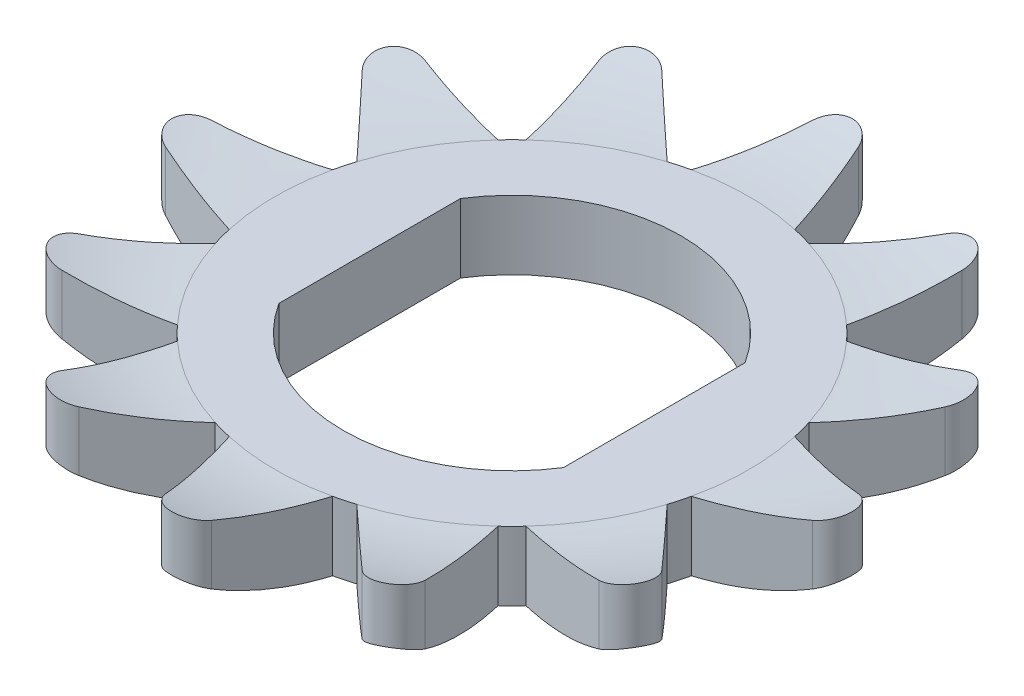
from build123d import *

# Parameters (mm, degrees)
BOSS_EXTRUDE1_DEPTH = 2.45
CUT_EXTRUDE1_DEPTH  = 2.45


with BuildPart() as part:
    # Sketch1 → Boss-Extrude1 (new body)
    with BuildSketch(Plane(origin=(0, 0, 0), x_dir=(1, 0, 0), z_dir=(0, 1, 0))):
        with BuildLine():
            Line((-1.5, 6.70936845), (-0.668522477, 9.387551675))
            ThreePointArc((-0.668522477, 9.387551675), (0, 9.88), (0.668522477, 9.387551675))
            Line((0.668522477, 9.387551675), (1.5, 6.70936845))
            ThreePointArc((1.5, 6.70936845), (1.779380935, 6.640740056), (2.055646119, 6.560483521))
            Line((2.055646119, 6.560483521), (4.114818389, 8.464119468))
            ThreePointArc((4.114818389, 8.464119468), (4.94, 8.556330989), (5.272733285, 7.795596991))
            Line((5.272733285, 7.795596991), (4.653722331, 5.060483521))
            ThreePointArc((4.653722331, 5.060483521), (4.861359121, 4.861359121), (5.060483521, 4.653722331))
            Line((5.060483521, 4.653722331), (7.795596991, 5.272733285))
            ThreePointArc((7.795596991, 5.272733285), (8.556330989, 4.94), (8.464119468, 4.114818389))
            Line((8.464119468, 4.114818389), (6.560483521, 2.055646119))
            ThreePointArc((6.560483521, 2.055646119), (6.640740056, 1.779380935), (6.70936845, 1.5))
            Line((6.70936845, 1.5), (9.387551675, 0.668522477))
            ThreePointArc((9.387551675, 0.668522477), (9.88, 0), (9.387551675, -0.668522477))
            Line((9.387551675, -0.668522477), (6.70936845, -1.5))
            ThreePointArc((6.70936845, -1.5), (6.640740056, -1.779380935), (6.560483521, -2.055646119))
            Line((6.560483521, -2.055646119), (8.464119468, -4.114818389))
            ThreePointArc((8.464119468, -4.114818389), (8.556330989, -4.94), (7.795596991, -5.272733285))
            Line((7.795596991, -5.272733285), (5.060483521, -4.653722331))
            ThreePointArc((5.060483521, -4.653722331), (4.861359121, -4.861359121), (4.653722331, -5.060483521))
            Line((4.653722331, -5.060483521), (5.272733285, -7.795596991))
            ThreePointArc((5.272733285, -7.795596991), (4.94, -8.556330989), (4.114818389, -8.464119468))
            Line((4.114818389, -8.464119468), (2.055646119, -6.560483521))
            ThreePointArc((2.055646119, -6.560483521), (1.779380935, -6.640740056), (1.5, -6.70936845))
            Line((1.5, -6.70936845), (0.668522477, -9.387551675))
            ThreePointArc((0.668522477, -9.387551675), (0, -9.88), (-0.668522477, -9.387551675))
            Line((-0.668522477, -9.387551675), (-1.5, -6.70936845))
            ThreePointArc((-1.5, -6.70936845), (-1.779380935, -6.640740056), (-2.055646119, -6.560483521))
            Line((-2.055646119, -6.560483521), (-4.114818389, -8.464119468))
            ThreePointArc((-4.114818389, -8.464119468), (-4.94, -8.556330989), (-5.272733285, -7.795596991))
            Line((-5.272733285, -7.795596991), (-4.653722331, -5.060483521))
            ThreePointArc((-4.653722331, -5.060483521), (-4.861359121, -4.861359121), (-5.060483521, -4.653722331))
            Line((-5.060483521, -4.653722331), (-7.795596991, -5.272733285))
            ThreePointArc((-7.795596991, -5.272733285), (-8.556330989, -4.94), (-8.464119468, -4.114818389))
            Line((-8.464119468, -4.114818389), (-6.560483521, -2.055646119))
            ThreePointArc((-6.560483521, -2.055646119), (-6.640740056, -1.779380935), (-6.70936845, -1.5))
            Line((-6.70936845, -1.5), (-9.387551675, -0.668522477))
            ThreePointArc((-9.387551675, -0.668522477), (-9.88, 0), (-9.387551675, 0.668522477))
            Line((-9.387551675, 0.668522477), (-6.70936845, 1.5))
            ThreePointArc((-6.70936845, 1.5), (-6.640740056, 1.779380935), (-6.560483521, 2.055646119))
            Line((-6.560483521, 2.055646119), (-8.464119468, 4.114818389))
            ThreePointArc((-8.464119468, 4.114818389), (-8.556330989, 4.94), (-7.795596991, 5.272733285))
            Line((-7.795596991, 5.272733285), (-5.060483521, 4.653722331))
            ThreePointArc((-5.060483521, 4.653722331), (-4.861359121, 4.861359121), (-4.653722331, 5.060483521))
            Line((-4.653722331, 5.060483521), (-5.272733285, 7.795596991))
            ThreePointArc((-5.272733285, 7.795596991), (-4.94, 8.556330989), (-4.114818389, 8.464119468))
            Line((-4.114818389, 8.464119468), (-2.055646119, 6.560483521))
            ThreePointArc((-2.055646119, 6.560483521), (-1.779380935, 6.640740056), (-1.5, 6.70936845))
        make_face()
    extrude(amount=BOSS_EXTRUDE1_DEPTH)

    # Sketch2 → Cut-Revolve1 (revolve, cut)
    with BuildSketch(Plane(origin=(0, 0, 0), x_dir=(0, 0, -1), z_dir=(1, 0, 0))):
        with BuildLine():
            Line((-6.875, 0), (-9.88, 0))
            Line((-9.88, 0), (-9.88, 0.85))
            ThreePointArc((-9.88, 0.85), (-8.436451648, 0.216588585), (-6.875, 0))
        make_face()
        with BuildLine():
            Line((-9.88, 2.45), (0, 2.45))
            Line((0, 2.45), (0, 2))
            Line((0, 2), (-6.875, 2))
            ThreePointArc((-6.875, 2), (-8.394253517, 2.113123734), (-9.88, 2.45))
        make_face()
    revolve(axis=Axis((0, 0, 0), (0, 1, 0)), mode=Mode.SUBTRACT)

    # Sketch3 → Cut-Extrude1 (cut)
    with BuildSketch(Plane(origin=(0, 2, 0), x_dir=(1, 0, 0), z_dir=(0, 1, 0))):
        with BuildLine():
            Line((-4.13, -2.636873148), (-4.13, 2.636873148))
            ThreePointArc((-4.13, 2.636873148), (0, 4.9), (4.13, 2.636873148))
            Line((4.13, 2.636873148), (4.13, -2.636873148))
            ThreePointArc((4.13, -2.636873148), (0, -4.9), (-4.13, -2.636873148))
        make_face()
    extrude(amount=-CUT_EXTRUDE1_DEPTH, mode=Mode.SUBTRACT)


solid = part.part
